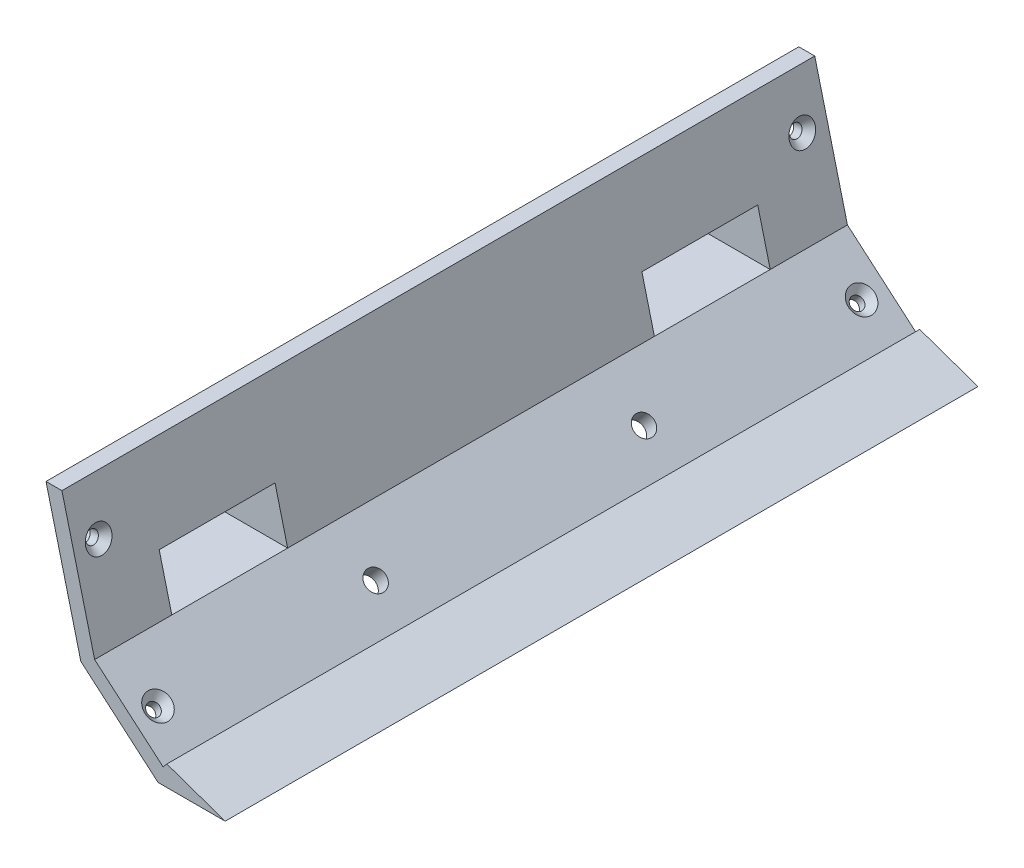
from build123d import *

# Parameters (mm, degrees)
SALIENTE_EXTRUIR1_DEPTH = 195
CROQUIS2_R              = 1.625
CORTAR_EXTRUIR1_DEPTH   = 4
CROQUIS3_R              = 1.625
CORTAR_EXTRUIR2_DEPTH   = 4
CROQUIS4_R              = 3.35997123
CORTAR_EXTRUIR3_DEPTH   = 1.8
CORTAR_EXTRUIR3_TAPER   = 44
CROQUIS5_R              = 3.35997123
CORTAR_EXTRUIR4_DEPTH   = 1.8
CORTAR_EXTRUIR4_TAPER   = 44
CORTAR_EXTRUIR5_DEPTH   = 50
CORTAR_EXTRUIR6_DEPTH   = 50
CROQUIS10_W             = 19.44351896
CROQUIS10_H             = 30
SALIENTE_EXTRUIR2_DEPTH = 2.209366
SALIENTE_EXTRUIR3_DEPTH = 2
SALIENTE_EXTRUIR4_DEPTH = 2
SALIENTE_EXTRUIR5_DEPTH = 16.206043
CORTAR_EXTRUIR8_START   = -16.206043
CORTAR_EXTRUIR8_DEPTH   = 16.206043
CROQUIS16_R             = 1.6
CORTAR_EXTRUIR9_DEPTH   = 4
SALIENTE_EXTRUIR6_START = -20
SALIENTE_EXTRUIR6_DEPTH = 20
SALIENTE_EXTRUIR7_START = -20
SALIENTE_EXTRUIR7_DEPTH = 20
CROQUIS19_R             = 2.625
CORTAR_EXTRUIR10_DEPTH  = 4
CORTAR_EXTRUIR11_START  = -177.915484
CORTAR_EXTRUIR11_DEPTH  = 160.720842


with BuildPart() as part:
    # Croquis1 → Saliente-Extruir1 (new body)
    with BuildSketch(Plane.XY):
        Polygon((77.008501507, 1.646687652), (77.984662833, 2.785594613), (93.086400798, -2.5), (75.699999998, -2.5), (55.699999998, 14.642073221), (46.67593732, 50.511923567), (50.800578307, 50.511923567), (59.268813207, 16.851439441), align=None)
    extrude(amount=-SALIENTE_EXTRUIR1_DEPTH)

    # Croquis2 → Cortar-Extruir1 (cut)
    with BuildSketch(Plane(origin=(55.848866467, 14.050342186, 0), x_dir=(0, 0, 1), z_dir=(-0.969781373, -0.24397559, 0))):
        with Locations((-188.625, 23.727396855)):
            Circle(CROQUIS2_R)
        with Locations((-6.375, 23.727396855)):
            Circle(CROQUIS2_R)
    extrude(amount=-CORTAR_EXTRUIR1_DEPTH, mode=Mode.SUBTRACT)

    # Croquis3 → Cortar-Extruir2 (cut)
    with BuildSketch(Plane(origin=(30.824200619, 35.963211942, 0), x_dir=(0.759271307, -0.650774217, 0), z_dir=(-0.650774217, -0.759271307, 0))):
        with Locations((47.262195378, -188.625)):
            Circle(CROQUIS3_R)
        with Locations((47.262195378, -6.375)):
            Circle(CROQUIS3_R)
    extrude(amount=-CORTAR_EXTRUIR2_DEPTH, mode=Mode.SUBTRACT)

    # Croquis4 → Cortar-Extruir3 (cut)
    with BuildSketch(Plane(origin=(33.427297488, 39.000297171, 0), x_dir=(0.759271307, -0.650774217, 0), z_dir=(0.650774217, 0.759271307, 0))):
        with Locations((47.262195378, 6.375)):
            Circle(CROQUIS4_R)
        with Locations((47.262195378, 188.625)):
            Circle(CROQUIS4_R)
    extrude(amount=-CORTAR_EXTRUIR3_DEPTH, taper=CORTAR_EXTRUIR3_TAPER, mode=Mode.SUBTRACT)

    # Croquis5 → Cortar-Extruir4 (cut)
    with BuildSketch(Plane(origin=(59.727991959, 15.026244545, 0), x_dir=(0, 0, -1), z_dir=(0.969781373, 0.24397559, 0))):
        with Locations((6.375, 23.727396855)):
            Circle(CROQUIS5_R)
        with Locations((188.625, 23.727396855)):
            Circle(CROQUIS5_R)
    extrude(amount=-CORTAR_EXTRUIR4_DEPTH, taper=CORTAR_EXTRUIR4_TAPER, mode=Mode.SUBTRACT)

    # Croquis7 → Cortar-Extruir5 (cut)
    with BuildSketch(Plane(origin=(0, 0, -195), x_dir=(-1, 0, 0), z_dir=(0, 0, -1))):
        Polygon((-59.268813207, 16.851439441), (-56.031337185, 29.720120048), (-51.906696198, 29.720120048), (-55.14417222, 16.851439441), align=None)
    extrude(amount=-CORTAR_EXTRUIR5_DEPTH, mode=Mode.SUBTRACT)

    # Croquis9 → Cortar-Extruir6 (cut)
    with BuildSketch(Plane.XY):
        Polygon((59.268813207, 16.851439441), (55.14417222, 16.851439441), (51.873659137, 29.851439441), (55.998300124, 29.851439441), align=None)
    extrude(amount=-CORTAR_EXTRUIR6_DEPTH, mode=Mode.SUBTRACT)

    # Croquis10 → Saliente-Extruir2 (add)
    with BuildSketch(Plane(origin=(0, 16.851439441, 0), x_dir=(1, 0, 0), z_dir=(0, 1, 0))):
        with Locations((49.547053727, 35)):
            Rectangle(CROQUIS10_W, CROQUIS10_H)
        with Locations((49.547053727, 160)):
            Rectangle(CROQUIS10_W, CROQUIS10_H)
    extrude(amount=-SALIENTE_EXTRUIR2_DEPTH)

    # Croquis11 → Saliente-Extruir3 (add)
    with BuildSketch(Plane.XZ.offset(-29.720120048)):
        Polygon((56.031337185, -145), (56.031337185, -175), (39.825294247, -175), (39.825294247, -164.3), (41.87529425, -164.3), (41.87529425, -155.7), (39.825294247, -155.7), (39.825294247, -145), align=None)
    extrude(amount=-SALIENTE_EXTRUIR3_DEPTH)

    # Croquis12 → Saliente-Extruir4 (add)
    with BuildSketch(Plane.XZ.offset(-29.851439441)):
        Polygon((55.998300124, -50), (55.998300124, -20), (39.825294247, -20), (39.825294247, -30.7), (41.87529425, -30.7), (41.87529425, -39.3), (39.825294247, -39.3), (39.825294247, -50), align=None)
    extrude(amount=-SALIENTE_EXTRUIR4_DEPTH)

    # Croquis14 → Saliente-Extruir5 (add)
    with BuildSketch(Plane.ZY.offset(-39.825294247)):
        Polygon((-137.75, 26.551439441), (-137.75, 19.010975035), (-145, 14.642073221), (-145, 31.720120048), align=None)
        Polygon((-12.75, 26.551439441), (-20, 31.851439441), (-20, 14.642073221), (-12.75, 19.051439441), align=None)
        Polygon((-57.25, 19.051439441), (-57.25, 26.551439441), (-50, 31.851439441), (-50, 14.642073221), align=None)
        Polygon((-182.25, 19.051439441), (-175, 14.642073221), (-175, 31.720120048), (-182.25, 26.551439441), align=None)
    extrude(amount=-SALIENTE_EXTRUIR5_DEPTH)

    # Croquis15 → Cortar-Extruir8 (cut)
    with BuildSketch(Plane.ZY.offset(-39.825294247).offset(CORTAR_EXTRUIR8_START)):
        Polygon((-182.25, 26.551439441), (-181.028612187, 27.422193028), (-181.028612187, 18.308605487), (-182.25, 19.051439441), align=None)
        Polygon((-12.75, 26.551439441), (-13.960933653, 27.436673697), (-13.960933653, 18.314963587), (-12.75, 19.051439441), align=None)
    extrude(amount=CORTAR_EXTRUIR8_DEPTH, mode=Mode.SUBTRACT)

    # Croquis16 → Cortar-Extruir9 (cut)
    with BuildSketch(Plane.ZY.offset(-39.825294247)):
        with Locations((-53.5, 22.801439441)):
            Circle(CROQUIS16_R)
        with Locations((-16.5, 22.801439441)):
            Circle(CROQUIS16_R)
        with Locations((-178.5, 22.801439441)):
            Circle(CROQUIS16_R)
        with Locations((-141.5, 22.801439441)):
            Circle(CROQUIS16_R)
    extrude(amount=-CORTAR_EXTRUIR9_DEPTH, mode=Mode.SUBTRACT)

    # Croquis17 → Saliente-Extruir6 (add)
    with BuildSketch(Plane.XY.offset(SALIENTE_EXTRUIR6_START)):
        Polygon((51.873659137, 29.851439441), (55.998300124, 29.851439441), (59.268813207, 16.851439441), (55.14417222, 16.851439441), align=None)
    extrude(amount=SALIENTE_EXTRUIR6_DEPTH)

    # Croquis18 → Saliente-Extruir7 (add)
    with BuildSketch(Plane(origin=(0, 0, -195), x_dir=(-1, 0, 0), z_dir=(0, 0, -1)).offset(SALIENTE_EXTRUIR7_START)):
        Polygon((-59.268813207, 16.851439441), (-55.14417222, 16.851439441), (-51.906696198, 29.720120048), (-56.031337185, 29.720120048), align=None)
    extrude(amount=SALIENTE_EXTRUIR7_DEPTH)

    # Croquis19 → Cortar-Extruir10 (cut)
    with BuildSketch(Plane(origin=(33.427297488, 39.000297171, 0), x_dir=(0.759271307, -0.650774217, 0), z_dir=(0.650774217, 0.759271307, 0))):
        with Locations((47.262195378, 62.75)):
            Circle(CROQUIS19_R)
        with Locations((47.262195378, 132.25)):
            Circle(CROQUIS19_R)
    extrude(amount=-CORTAR_EXTRUIR10_DEPTH, mode=Mode.SUBTRACT)

    # Croquis20 → Cortar-Extruir11 (cut)
    with BuildSketch(Plane(origin=(0, 0, -195), x_dir=(-1, 0, 0), z_dir=(0, 0, -1)).offset(CORTAR_EXTRUIR11_START)):
        Polygon((-56.031337185, 29.720120048), (-56.031337185, 31.851439441), (-55.495144266, 31.851439441), align=None)
    extrude(amount=CORTAR_EXTRUIR11_DEPTH, mode=Mode.SUBTRACT)


solid = part.part
